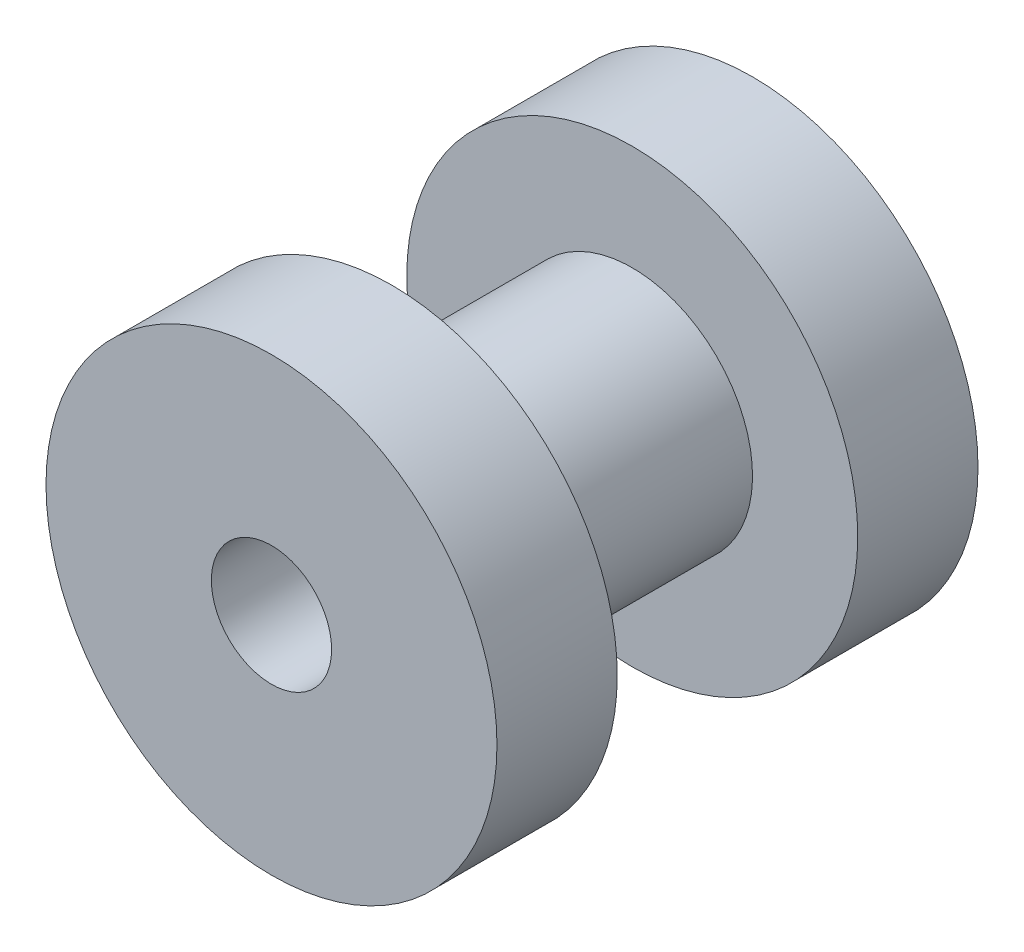
from build123d import *

# Parameters (mm, degrees)
SKETCH1_R               = 4.7625
BOSS_EXTRUDE1_DEPTH     = 5.08
SKETCH2_W               = 5.08
SKETCH2_H               = 4.445
SKETCH3_R               = 1.27
CUT_EXTRUDE1_DEPTH      = 1
CUT_EXTRUDE1_DEPTH_BACK = 11.16


with BuildPart() as part:
    # Sketch1 → Boss-Extrude1 (new body, symmetric)
    with BuildSketch(Plane.XY):
        Circle(SKETCH1_R)
    extrude(amount=BOSS_EXTRUDE1_DEPTH, both=True)

    # Sketch2 → Cut-Revolve1 (revolve, cut)
    with BuildSketch(Plane(origin=(0, 0, 0), x_dir=(0, 0, -1), z_dir=(1, 0, 0)), mode=Mode.PRIVATE) as cut_revolve1_sk:
        with Locations((0, 4.7625)):
            Rectangle(SKETCH2_W, SKETCH2_H)
    revolve(cut_revolve1_sk.sketch.rotate(Axis((0, 0, 0), (0, 0, -1)), 180), axis=Axis((0, 0, 0), (0, 0, -1)), mode=Mode.SUBTRACT)  # turned: the seam where the file's is

    # Sketch3 → Cut-Extrude1 (cut, two sides)
    with BuildSketch(Plane.XY.offset(5.08)) as cut_extrude1_sk:
        Circle(SKETCH3_R)
    extrude(amount=CUT_EXTRUDE1_DEPTH, mode=Mode.SUBTRACT)
    extrude(cut_extrude1_sk.sketch, amount=-CUT_EXTRUDE1_DEPTH_BACK, mode=Mode.SUBTRACT)


solid = part.part
